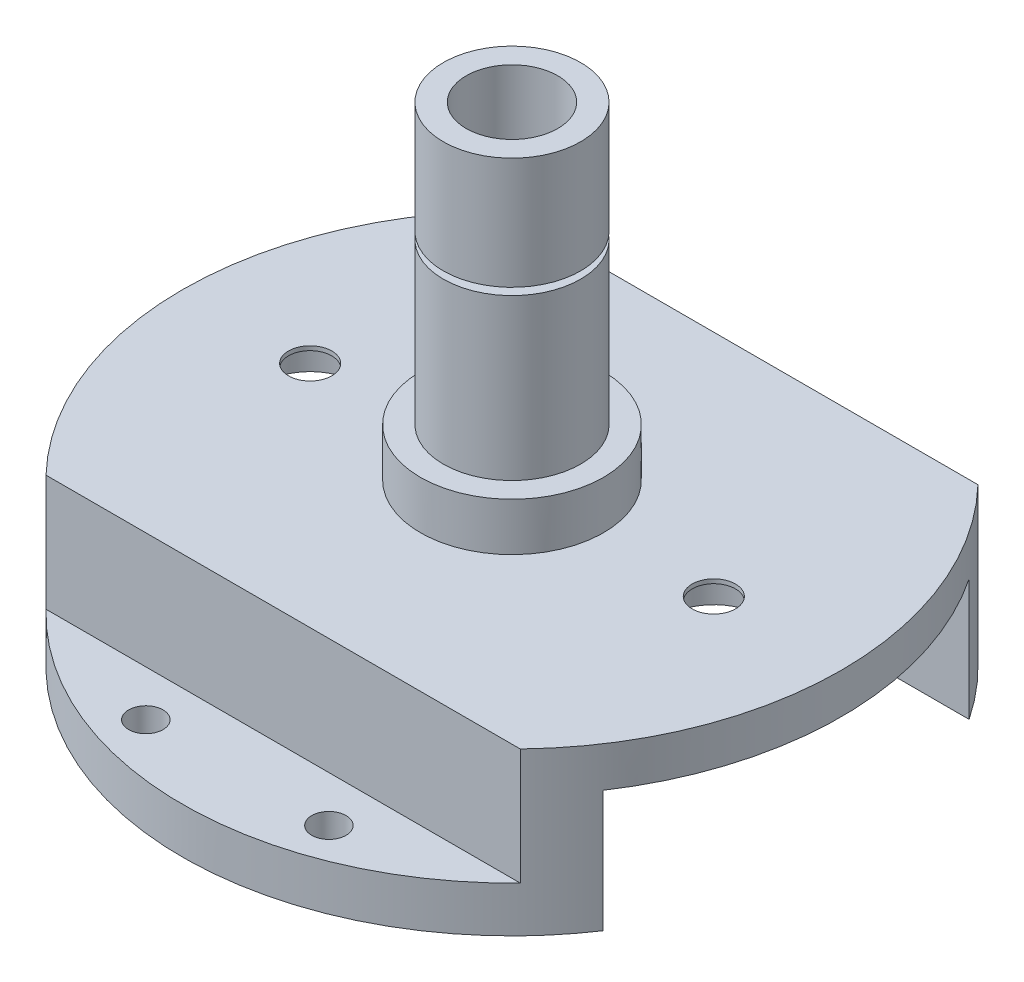
from build123d import *

# Parameters (mm, degrees)
SKETCH1_R           = 12.7
SKETCH1_R_2         = 6.35
BOSS_EXTRUDE1_DEPTH = 6.6548
SKETCH2_R           = 9.525
SKETCH2_R_2         = 6.35
BOSS_EXTRUDE2_DEPTH = 38.735
SKETCH3_OUTSIDE_W   = 38.976
SKETCH3_OUTSIDE_H   = 38.976
SKETCH3_OUTSIDE_R   = 7.4676
CUT_EXTRUDE1_DEPTH  = 0.9906
SKETCH5_R           = 45.72
SKETCH5_R_2         = 9.525
SKETCH5_R_3         = 3
BOSS_EXTRUDE4_DEPTH = 5.587499906
SKETCH6_R           = 6.5
CUT_EXTRUDE5_DEPTH  = 4.999999906
BOSS_EXTRUDE5_DEPTH = 16.875
SKETCH9_R           = 2.38125
CUT_EXTRUDE7_DEPTH  = 22.4625
SKETCH12_W          = 91.44
SKETCH12_H          = 13.97
CUT_EXTRUDE10_DEPTH = 16.1125


with BuildPart() as part:
    # Sketch1 → Boss-Extrude1 (new body)
    with BuildSketch(Plane(origin=(0, 0, 0), x_dir=(1, 0, 0), z_dir=(0, 1, 0))):
        Circle(SKETCH1_R)
        Circle(SKETCH1_R_2, mode=Mode.SUBTRACT)
    extrude(amount=BOSS_EXTRUDE1_DEPTH)

    # Sketch2 → Boss-Extrude2 (add)
    with BuildSketch(Plane(origin=(0, 6.6548, 0), x_dir=(1, 0, 0), z_dir=(0, 1, 0))):
        Circle(SKETCH2_R)
        Circle(SKETCH2_R_2, mode=Mode.SUBTRACT)
    extrude(amount=BOSS_EXTRUDE2_DEPTH)

    # Sketch3 outside → Cut-Extrude1 (cut)
    with BuildSketch(Plane(origin=(0, 28.8798, 0), x_dir=(-1, 0, 0), z_dir=(0, 1, 0))):
        Rectangle(SKETCH3_OUTSIDE_W, SKETCH3_OUTSIDE_H)
        Circle(SKETCH3_OUTSIDE_R, mode=Mode.SUBTRACT)
    extrude(amount=CUT_EXTRUDE1_DEPTH, mode=Mode.SUBTRACT)

    # Sketch5 → Boss-Extrude4 (add)
    with BuildSketch(Plane.XZ):
        Circle(SKETCH5_R)
        Circle(SKETCH5_R_2, mode=Mode.SUBTRACT)
        with Locations((28, 0)):
            Circle(SKETCH5_R_3, mode=Mode.SUBTRACT)
        with Locations((-28, 0)):
            Circle(SKETCH5_R_3, mode=Mode.SUBTRACT)
    extrude(amount=BOSS_EXTRUDE4_DEPTH)

    # Sketch6 → Cut-Extrude5 (cut)
    with BuildSketch(Plane.XZ.offset(5.587499906)):
        with Locations((-28, 0)):
            Circle(SKETCH6_R)
        with Locations((28, 0)):
            Circle(SKETCH6_R)
    extrude(amount=-CUT_EXTRUDE5_DEPTH, mode=Mode.SUBTRACT)

    # Sketch8 → Boss-Extrude5 (add)
    with BuildSketch(Plane.XZ.offset(5.587499906)):
        with BuildLine():
            Line((38.01523905, -25.4), (-38.01523905, -25.4))
            ThreePointArc((-38.01523905, -25.4), (0, -45.72), (38.01523905, -25.4))
        make_face()
        with BuildLine():
            ThreePointArc((38.01523905, 25.4), (0, 45.72), (-38.01523905, 25.4))
            Line((-38.01523905, 25.4), (38.01523905, 25.4))
        make_face()
    extrude(amount=BOSS_EXTRUDE5_DEPTH)

    # Sketch9 → Cut-Extrude7 (cut)
    with BuildSketch(Plane.XZ.offset(22.462499906)):
        with Locations((12.7, 38.1)):
            Circle(SKETCH9_R)
        with Locations((-12.7, 38.1)):
            Circle(SKETCH9_R)
        with Locations((-12.7, -38.1)):
            Circle(SKETCH9_R)
        with Locations((12.7, -38.1)):
            Circle(SKETCH9_R)
    extrude(amount=-CUT_EXTRUDE7_DEPTH, mode=Mode.SUBTRACT)

    # Sketch12 → Cut-Extrude10 (cut)
    with BuildSketch(Plane(origin=(0, 0, 0), x_dir=(1, 0, 0), z_dir=(0, 1, 0))):
        with Locations((0, -38.735)):
            Rectangle(SKETCH12_W, SKETCH12_H)
        with Locations((0, 38.735)):
            Rectangle(SKETCH12_W, SKETCH12_H)
    extrude(amount=-CUT_EXTRUDE10_DEPTH, mode=Mode.SUBTRACT)


solid = part.part
